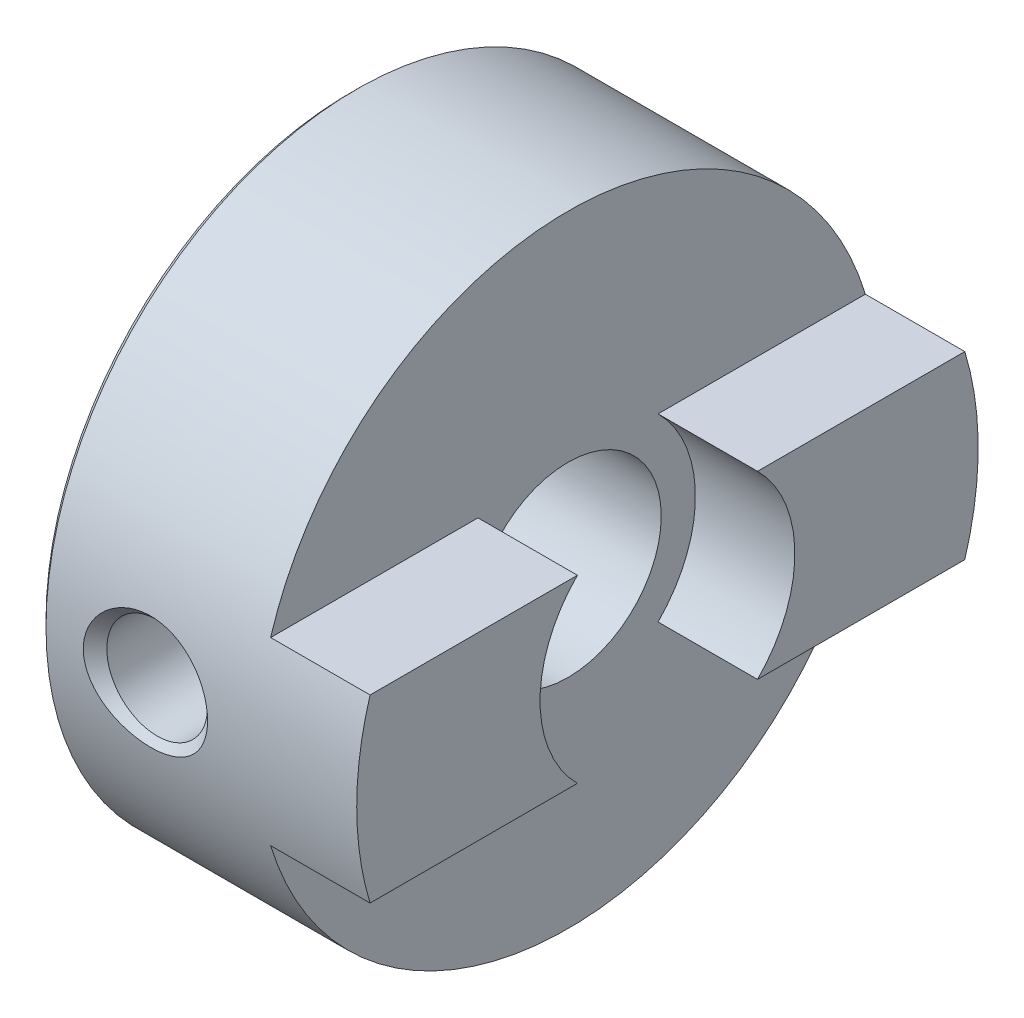
from build123d import *

# Parameters (mm, degrees)
SKETCH2_W          = 3.2
SKETCH2_H          = 4.1
SKETCH3_W          = 22
SKETCH3_H          = 21
SKETCH3_W_2        = 20
SKETCH3_H_2        = 5.8
CUT_EXTRUDE1_DEPTH = 3.2


with BuildPart() as part:
    # Sketch1 → Revolve1 (revolve)
    with BuildSketch(Plane.XY):
        Polygon((0, 9.8), (0, 3), (10.2, 3), (10.2, 10), (0.2, 10), align=None)
    revolve(axis=Axis((10.2, 0, 0), (-1, 0, 0)))

    # Sketch2 → Cut-Revolve1 (revolve, cut)
    with BuildSketch(Plane.XY):
        with Locations((8.6, 2.05)):
            Rectangle(SKETCH2_W, SKETCH2_H)
    revolve(axis=Axis((10.2, 0, 0), (-1, 0, 0)), mode=Mode.SUBTRACT)

    # Sketch3 → Cut-Extrude1 (cut)
    with BuildSketch(Plane(origin=(10.2, 0, 0), x_dir=(0, 0, -1), z_dir=(1, 0, 0))):
        Rectangle(SKETCH3_W, SKETCH3_H)
        Rectangle(SKETCH3_W_2, SKETCH3_H_2, mode=Mode.SUBTRACT)
    extrude(amount=-CUT_EXTRUDE1_DEPTH, mode=Mode.SUBTRACT)

    # Sketch4 → Cut-Revolve2 (revolve, cut)
    with BuildSketch(Plane(origin=(3.4, 0, 0), x_dir=(0, 0, -1), z_dir=(1, 0, 0))):
        Polygon((-10, 0), (-10, 2), (-9.621, 1.621), (0, 1.621), (0, 0), align=None)
    revolve(axis=Axis((3.4, 0, 0), (0, 0, 1)), mode=Mode.SUBTRACT)

    # Sketch5 → Cut-Revolve3 (revolve, cut)
    with BuildSketch(Plane(origin=(3.4, 0, 0), x_dir=(0, 0, -1), z_dir=(1, 0, 0))):
        Polygon((0, -10), (-2, -10), (-1.621, -9.621), (-1.621, 0), (0, 0), align=None)
    revolve(axis=Axis((3.4, 0, 0), (0, -1, 0)), mode=Mode.SUBTRACT)


solid = part.part
